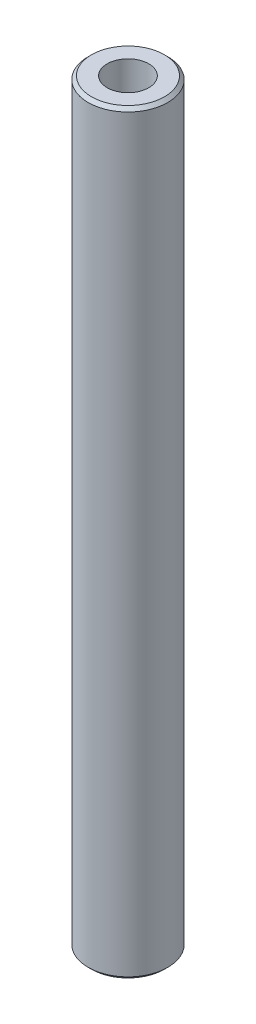
from build123d import *

# Parameters (mm, degrees)
CROQUIS2_R                = 4.7625
SALIENTE_EXTRUIR1_DEPTH   = 45.24375
CHAFL_N1_SIZE             = 0.396875
CLEARANCE_HOLE_DEPTH      = 46.742318771
CLEARANCE_HOLE_DEPTH_BACK = 46.742318771
CROQUIS4_R                = 2.4892


with BuildPart() as part:
    # Croquis2 → Saliente-Extruir1 (new, symmetric)
    with BuildSketch(Plane(origin=(0, 0, 0), x_dir=(1, 0, 0), z_dir=(0, 1, 0))):
        Circle(CROQUIS2_R)
    extrude(amount=SALIENTE_EXTRUIR1_DEPTH, both=True)

    # Chaflán1
    chafl_n1_edges = [part.edges().sort_by_distance(p)[0] for p in [
        (-4.7625, -45.24375, 0),
        (-4.7625, 45.24375, 0),
    ]]
    chamfer(chafl_n1_edges, length=CHAFL_N1_SIZE)

    # Croquis4 → Clearance Hole (cut, two sides: drawn at the far end of the back side and taken through both)
    with BuildSketch(Plane(origin=(0, 0, 0), x_dir=(1, 0, 0), z_dir=(0, 1, 0)).offset(-CLEARANCE_HOLE_DEPTH_BACK)):
        Circle(CROQUIS4_R)
    extrude(amount=CLEARANCE_HOLE_DEPTH + CLEARANCE_HOLE_DEPTH_BACK, mode=Mode.SUBTRACT)


solid = part.part
